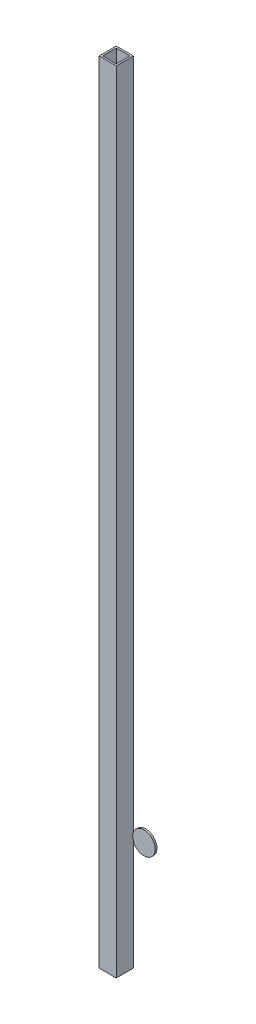
from build123d import *

# Parameters (mm, degrees)
SKETCH1_W                 = 25.4
SKETCH1_H                 = 25.4
SKETCH1_W_2               = 20.32
SKETCH1_H_2               = 20.32
EXTRUSION_1X1X0_1_1_DEPTH = 1168.4
SKETCH3_R                 = 16.642304713
BOSS_EXTRUDE1_DEPTH       = 1.27


with BuildPart() as part:
    # Sketch1 → Extrusion 1X1X0.1(1) (new body)
    with BuildSketch(Plane(origin=(0, 0, 0), x_dir=(-1, 0, 0), z_dir=(0, 1, 0))):
        with Locations((12.7, 12.7)):
            Rectangle(SKETCH1_W, SKETCH1_H)
        with Locations((12.7, 12.7)):
            Rectangle(SKETCH1_W_2, SKETCH1_H_2, mode=Mode.SUBTRACT)
    extrude(amount=EXTRUSION_1X1X0_1_1_DEPTH)


with BuildPart() as body_2:
    # Sketch3 → Boss-Extrude1 (new, symmetric)
    with BuildSketch(Plane(origin=(0, -24.723733652, 0), x_dir=(1, 0, 0), z_dir=(0, 0, 1))):
        with Locations((16.831979456, 194.250250367)):
            Circle(SKETCH3_R)
    extrude(amount=BOSS_EXTRUDE1_DEPTH, both=True)


solid = Compound([part.part, body_2.part])
